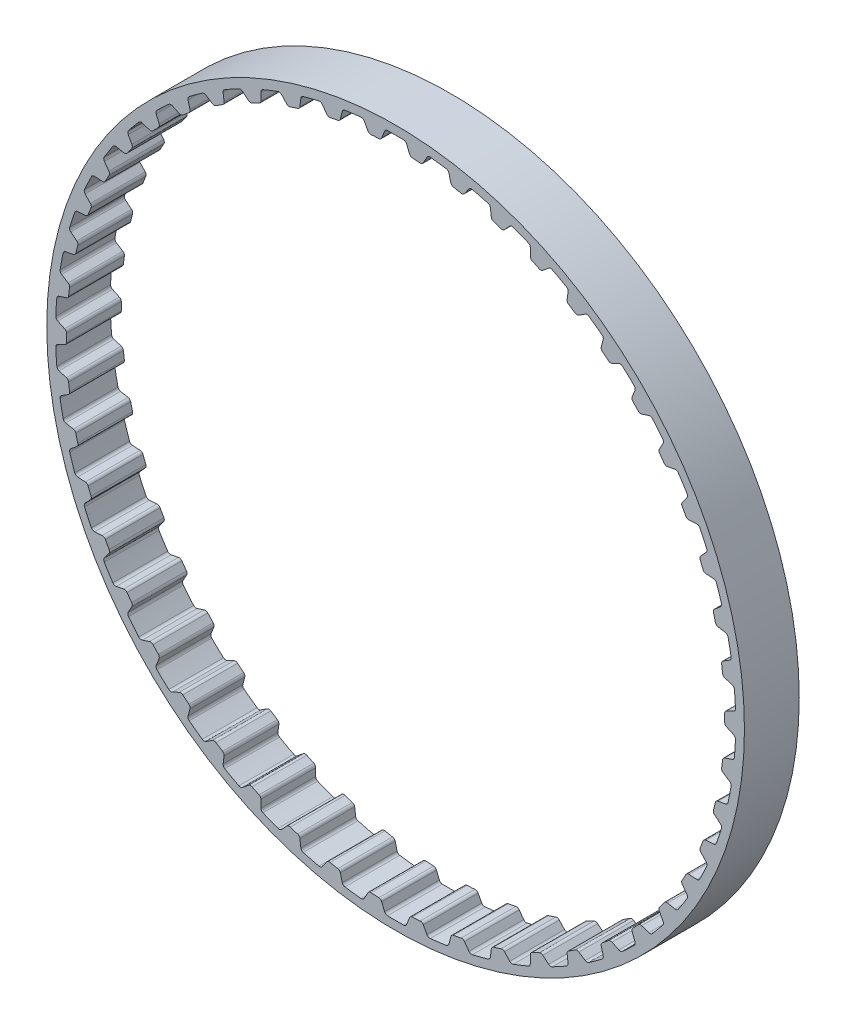
from build123d import *

# Parameters (mm, degrees)
SKETCH1_R           = 40.425389691
SKETCH1_R_2         = 38.139389691
BOSS_EXTRUDE1_DEPTH = 3.175
CUT_EXTRUDE1_DEPTH  = 3.175
CIRPATTERN1_COUNT   = 50


with BuildPart() as part:
    # Sketch1 → Boss-Extrude1 (new body, symmetric)
    with BuildSketch(Plane.XY):
        Circle(SKETCH1_R)
        Circle(SKETCH1_R_2, mode=Mode.SUBTRACT)
    extrude(amount=BOSS_EXTRUDE1_DEPTH, both=True)

    # Sketch3 → Cut-Extrude1 (cut, symmetric)
    with BuildSketch(Plane.XY):
        with BuildLine():
            Line((-1.941253917, 38.089953784), (1.941253917, 38.089953784))
            ThreePointArc((1.941253917, 38.089953784), (1.73799992, 38.161284352), (1.605914141, 38.33144188))
            Line((1.605914141, 38.33144188), (1.282626025, 39.156375924))
            ThreePointArc((1.282626025, 39.156375924), (1.146323763, 39.329526626), (0.936951974, 39.398250175))
            ThreePointArc((0.936951974, 39.398250175), (0, 39.409389691), (-0.936951974, 39.398250175))
            ThreePointArc((-0.936951974, 39.398250175), (-1.146323763, 39.329526626), (-1.282626025, 39.156375924))
            Line((-1.282626025, 39.156375924), (-1.605914141, 38.33144188))
            ThreePointArc((-1.605914141, 38.33144188), (-1.73799992, 38.161284352), (-1.941253917, 38.089953784))
        make_face()
    cut_extrude1 = extrude(amount=CUT_EXTRUDE1_DEPTH, both=True, mode=Mode.SUBTRACT)

    # CirPattern1: Cut-Extrude1 ×50 about axis
    cirpattern1_axis = Axis((0, 0, 0), (0, 0, 1))
    for i in range(1, CIRPATTERN1_COUNT):
        add(cut_extrude1.rotate(cirpattern1_axis, i * 360 / CIRPATTERN1_COUNT), mode=Mode.SUBTRACT)


solid = part.part
